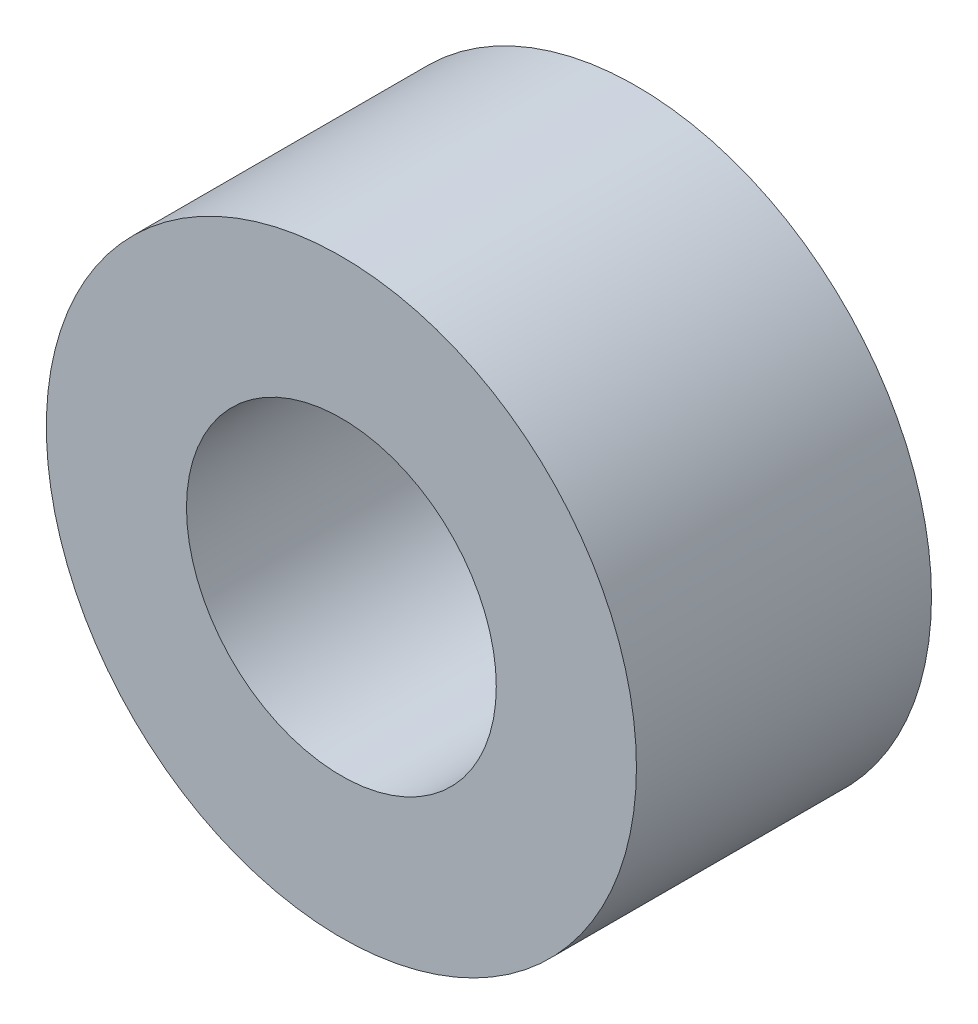
from build123d import *

# Parameters (mm, degrees)
SKETCH1_R           = 4
SKETCH1_R_2         = 2.1
EXTRUDE1_DEPTH      = 2
EXTRUDE1_DEPTH_BACK = 2


with BuildPart() as part:
    # Sketch1 → Extrude1 (new body, two sides)
    with BuildSketch(Plane.XY) as extrude1_sk:
        Circle(SKETCH1_R)
        Circle(SKETCH1_R_2, mode=Mode.SUBTRACT)
    extrude(amount=EXTRUDE1_DEPTH)
    extrude(extrude1_sk.sketch, amount=-EXTRUDE1_DEPTH_BACK)


solid = part.part
